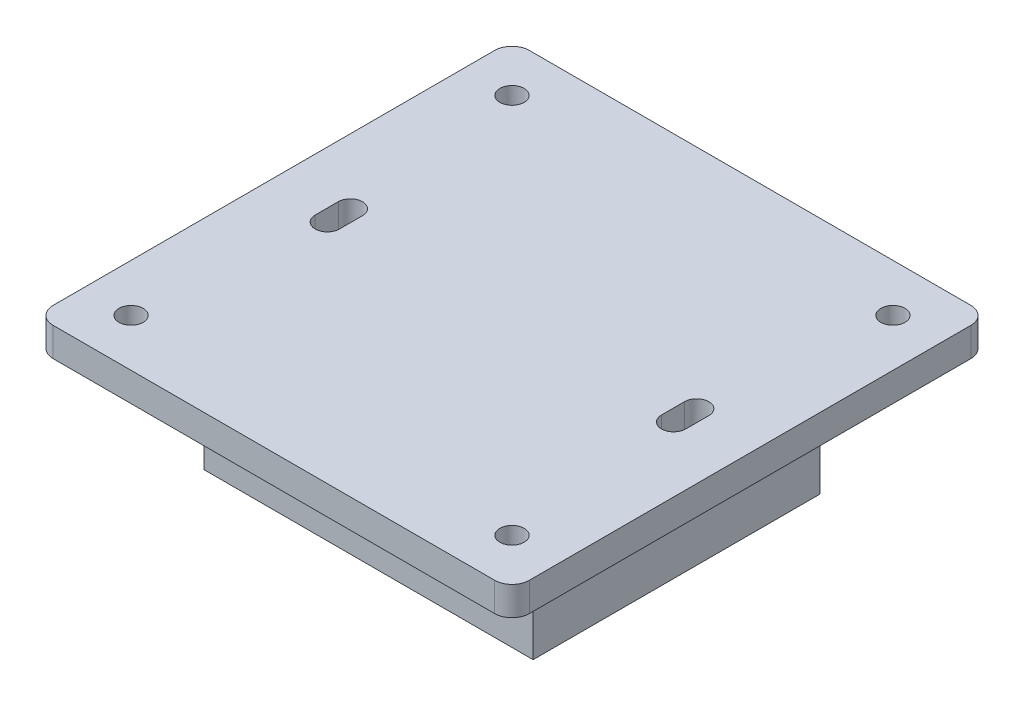
from build123d import *

# Parameters (mm, degrees)
SKETCH_1_R      = 2.1
EXTRUDE_1_DEPTH = 5
SKETCH_2_W      = 57
SKETCH_2_H      = 49.677447992
EXTRUDE_2_DEPTH = 20


with BuildPart() as part:
    # Эскиз1 → Бобышка-Вытянуть1 (new body)
    with BuildSketch(Plane(origin=(0, 0, 0), x_dir=(1, 0, 0), z_dir=(0, 1, 0))):
        with BuildLine():
            Line((-38.25, -41.25), (38.25, -41.25))
            ThreePointArc((38.25, -41.25), (40.371320344, -40.371320344), (41.25, -38.25))
            Line((41.25, -38.25), (41.25, 38.25))
            ThreePointArc((41.25, 38.25), (40.371320344, 40.371320344), (38.25, 41.25))
            Line((38.25, 41.25), (-38.25, 41.25))
            ThreePointArc((-38.25, 41.25), (-40.371320344, 40.371320344), (-41.25, 38.25))
            Line((-41.25, 38.25), (-41.25, -38.25))
            ThreePointArc((-41.25, -38.25), (-40.371320344, -40.371320344), (-38.25, -41.25))
        make_face()
        with Locations((-33, 33)):
            Circle(SKETCH_1_R, mode=Mode.SUBTRACT)
        with Locations((33, 33)):
            Circle(SKETCH_1_R, mode=Mode.SUBTRACT)
        with Locations((33, -33)):
            Circle(SKETCH_1_R, mode=Mode.SUBTRACT)
        with Locations((-33, -33)):
            Circle(SKETCH_1_R, mode=Mode.SUBTRACT)
        with BuildLine():
            Line((-32.1, 2), (-32.1, -2))
            ThreePointArc((-32.1, -2), (-30, -4.1), (-27.9, -2))
            Line((-27.9, -2), (-27.9, 2))
            ThreePointArc((-27.9, 2), (-30, 4.1), (-32.1, 2))
        make_face(mode=Mode.SUBTRACT)
        with BuildLine():
            Line((32.1, -2), (32.1, 2))
            ThreePointArc((32.1, 2), (30, 4.1), (27.9, 2))
            Line((27.9, 2), (27.9, -2))
            ThreePointArc((27.9, -2), (30, -4.1), (32.1, -2))
        make_face(mode=Mode.SUBTRACT)
    extrude(amount=EXTRUDE_1_DEPTH)

    # Эскиз2 → Бобышка-Вытянуть2 (add)
    with BuildSketch(Plane.XZ):
        Rectangle(SKETCH_2_W, SKETCH_2_H)
    extrude(amount=EXTRUDE_2_DEPTH)


solid = part.part
